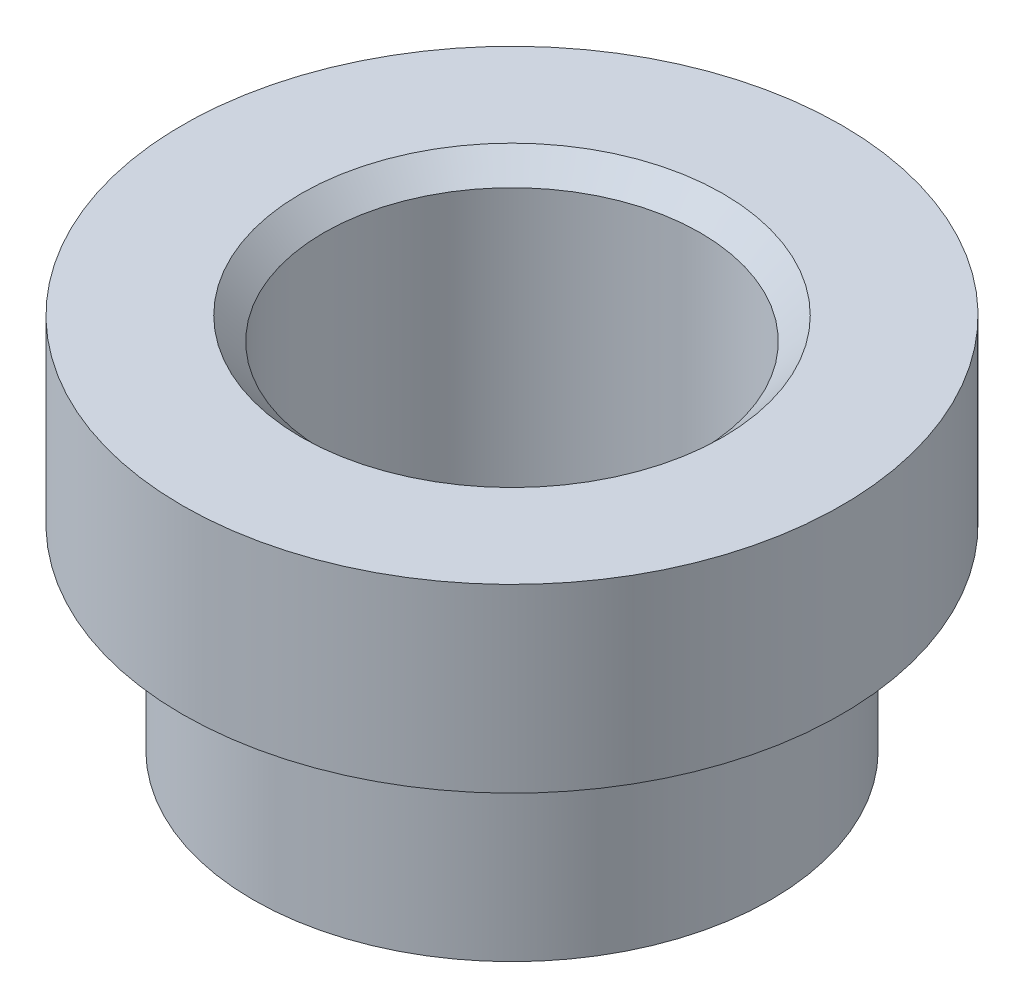
from build123d import *

# Parameters (mm, degrees)
CHAMFER1_SIZE = 0.762


with BuildPart() as part:
    # Sketch1 → Revolve1 (revolve)
    with BuildSketch(Plane.XY):
        Polygon((8.73125, 0), (11.1125, 0), (11.1125, 6.096), (6.35, 6.096), (6.35, -6.604), (8.73125, -6.604), align=None)
    revolve(axis=Axis((0, 0, 0), (0, -1, 0)))

    # Chamfer1
    chamfer1_edges = [part.edges().sort_by_distance(p)[0] for p in [
        (-6.35, 6.096, 0),
    ]]
    chamfer(chamfer1_edges, length=CHAMFER1_SIZE)


solid = part.part
